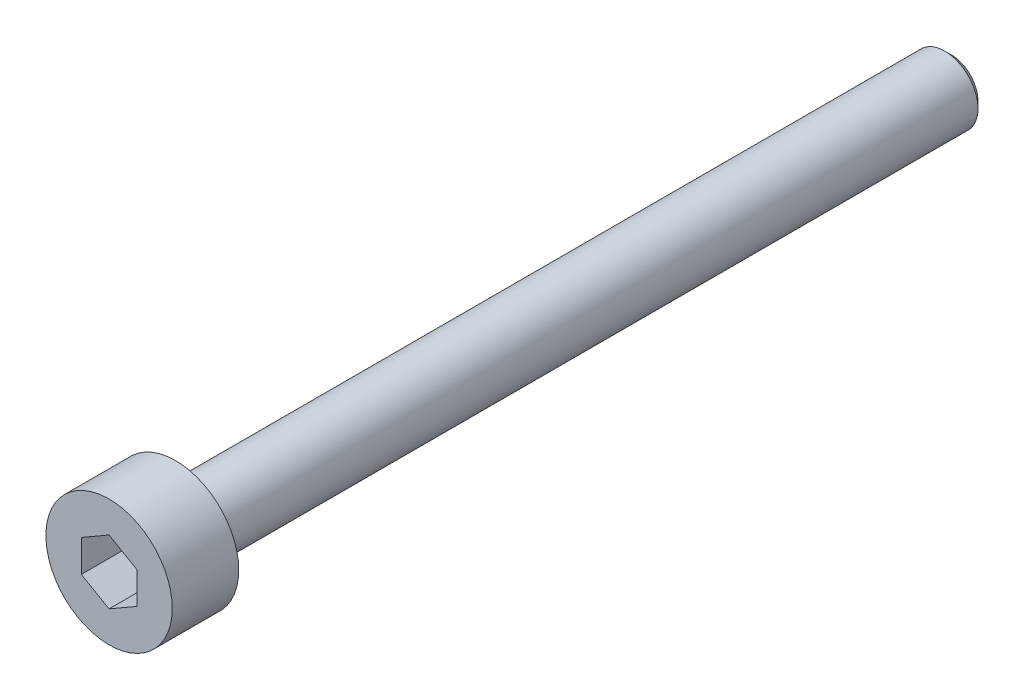
from build123d import *

# Parameters (mm, degrees)
SKETCH1_R           = 2.85
BOSS_EXTRUDE1_DEPTH = 3
SKETCH2_R           = 1.5
BOSS_EXTRUDE2_DEPTH = 35
CHAMFER1_SIZE       = 0.3
CUT_EXTRUDE1_DEPTH  = 2


with BuildPart() as part:
    # Sketch1 → Boss-Extrude1 (new body)
    with BuildSketch(Plane.XY):
        Circle(SKETCH1_R)
    extrude(amount=BOSS_EXTRUDE1_DEPTH)

    # Sketch2 → Boss-Extrude2 (add)
    with BuildSketch(Plane(origin=(0, 0, 0), x_dir=(-1, 0, 0), z_dir=(0, 0, -1))):
        Circle(SKETCH2_R)
    extrude(amount=BOSS_EXTRUDE2_DEPTH)

    # Chamfer1
    chamfer1_edges = [part.edges().sort_by_distance(p)[0] for p in [
        (1.5, 0, -35),
    ]]
    chamfer(chamfer1_edges, length=CHAMFER1_SIZE)

    # Sketch3 → Cut-Extrude1 (cut)
    with BuildSketch(Plane.XY.offset(3)):
        Polygon((0, 1.443375673), (-1.25, 0.721687836), (-1.25, -0.721687836), (0, -1.443375673), (1.25, -0.721687836), (1.25, 0.721687836), align=None)
    extrude(amount=-CUT_EXTRUDE1_DEPTH, mode=Mode.SUBTRACT)


solid = part.part
